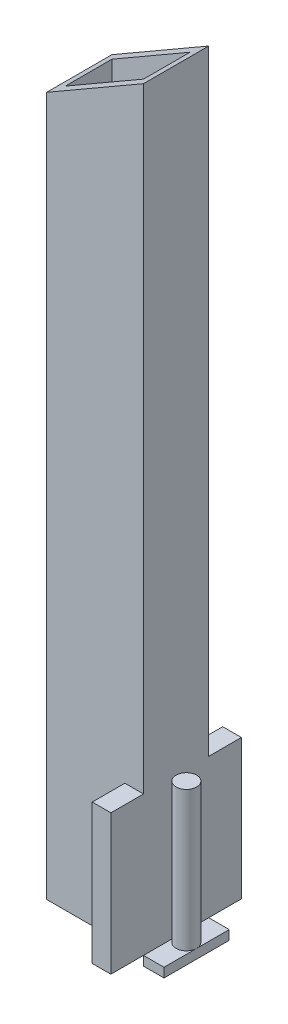
from build123d import *

# Parameters (mm, degrees)
BOSS_EXTRUDE1_DEPTH = 3.5
SHELL1_T            = -1
SKETCH3_W           = 2
SKETCH3_H           = 3.5
SKETCH3_R           = 1.1
BOSS_EXTRUDE2_DEPTH = 15
SKETCH3_6_W         = 2.2
SKETCH3_6_H         = 7
BOSS_EXTRUDE5_DEPTH = 1


with BuildPart() as part:
    # Sketch2 → Boss-Extrude1 (new, symmetric)
    with BuildSketch(Plane.XY):
        Polygon((0, 0), (0, 75), (10.392304845, 81), (10.392304845, 0), align=None)
    extrude(amount=BOSS_EXTRUDE1_DEPTH, both=True)

    # Shell1
    shell1_openings = [part.faces().sort_by_distance(p)[0] for p in [
        (5.196152423, 0, 0),
        (5.196152423, 78, 0),
    ]]
    offset(amount=SHELL1_T, openings=shell1_openings, kind=Kind.INTERSECTION)

    # Sketch3 → Boss-Extrude2 (add)
    with BuildSketch(Plane(origin=(0, 0, 0), x_dir=(1, 0, 0), z_dir=(0, 1, 0))):
        with Locations((9.392304845, -5.25)):
            Rectangle(SKETCH3_W, SKETCH3_H)
        with Locations((9.392304845, 5.25)):
            Rectangle(SKETCH3_W, SKETCH3_H)
        with Locations((11.492304845, 0)):
            Circle(SKETCH3_R)
    extrude(amount=BOSS_EXTRUDE2_DEPTH)


with BuildPart() as boss_extrude2_piece_1:
    # of the separate pieces the step leaves, piece 1, a body of its own (boss_extrude2_pieces)
    add(part.part.solids().sort_by_distance((0, 0, -3.5))[0])


with BuildPart() as boss_extrude2_piece_2:
    # of the separate pieces the step leaves, piece 2, a body of its own (boss_extrude2_pieces)
    add(part.part.solids().sort_by_distance((12.592304845, 0, 0))[0])

    # Sketch3_6 → Boss-Extrude5 (add)
    with BuildSketch(Plane(origin=(0, 0, 0), x_dir=(1, 0, 0), z_dir=(0, 1, 0))):
        with Locations((11.492304845, 0)):
            Rectangle(SKETCH3_6_W, SKETCH3_6_H)
    extrude(amount=-BOSS_EXTRUDE5_DEPTH)


solid = Compound([boss_extrude2_piece_1.part, boss_extrude2_piece_2.part])
